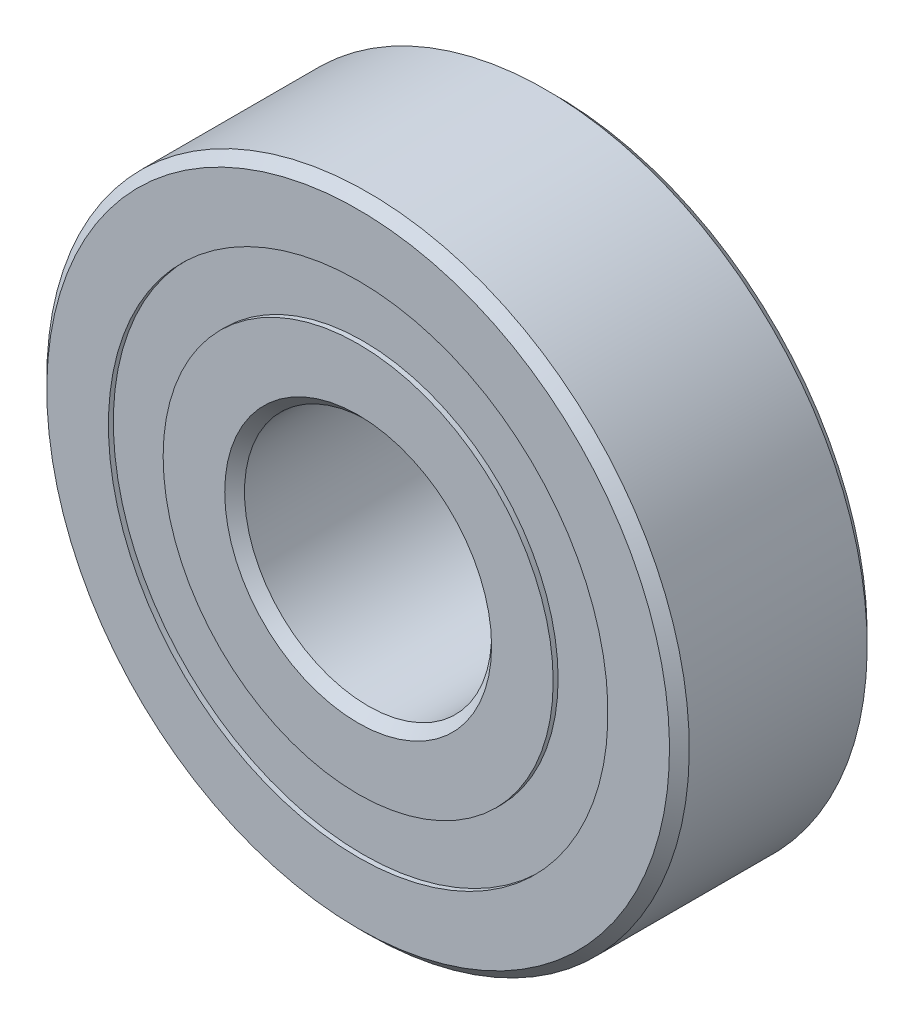
from build123d import *

# Parameters (mm, degrees)
CIRPATTERN1_COUNT = 10
SKETCH5_W         = 1.705369704
SKETCH5_H         = 2.215384616


with BuildPart() as part:
    # Sketch7 → Revolve6 (revolve)
    with BuildSketch(Plane(origin=(0, 0, 0), x_dir=(0, 0, -1), z_dir=(1, 0, 0))):
        with BuildLine():
            Line((3.6, 13), (4, 12.6))
            Line((4, 12.6), (4, 10.107692308))
            Line((4, 10.107692308), (1.777777778, 10.107692308))
            ThreePointArc((1.777777778, 10.107692308), (0, 11.094630296), (-1.777777778, 10.107692308))
            Line((-1.777777778, 10.107692308), (-4, 10.107692308))
            Line((-4, 10.107692308), (-4, 12.6))
            Line((-4, 12.6), (-3.6, 13))
            Line((-3.6, 13), (3.6, 13))
        make_face()
    revolve(axis=Axis((0, 0, 4), (0, 0, -1)))


with BuildPart() as body_2:
    # Sketch3 → Revolve3 (revolve)
    with BuildSketch(Plane(origin=(0, 0, 0), x_dir=(0, 0, -1), z_dir=(1, 0, 0))):
        with BuildLine():
            Line((-3.6, 5), (-4, 5.4))
            Line((-4, 5.4), (-4, 7.892307692))
            Line((-4, 7.892307692), (-1.777777778, 7.892307692))
            ThreePointArc((-1.777777778, 7.892307692), (0, 6.905369704), (1.777777778, 7.892307692))
            Line((1.777777778, 7.892307692), (4, 7.892307692))
            Line((4, 7.892307692), (4, 5.4))
            Line((4, 5.4), (3.6, 5))
            Line((3.6, 5), (-3.6, 5))
        make_face()
    revolve(axis=Axis((0, 0, 4), (0, 0, -1)))


with BuildPart() as body_3:
    # Sketch4 → Revolve4 (revolve)
    with BuildSketch(Plane(origin=(0, 0, 0), x_dir=(0, 0, -1), z_dir=(1, 0, 0))):
        with BuildLine():
            Line((-2.094630296, 9), (2.094630296, 9))
            ThreePointArc((2.094630296, 9), (0, 11.094630296), (-2.094630296, 9))
        make_face()
    revolve(axis=Axis((0, 9, 2.094630296), (0, 0, -1)))


with BuildPart() as cirpattern1_1:
    # CirPattern1: pattern copy
    add(body_3.part.rotate(Axis((0, 0, 0), (0, 0, 1)), 1 * 360 / CIRPATTERN1_COUNT))


with BuildPart() as cirpattern1_2:
    # CirPattern1: pattern copy
    add(body_3.part.rotate(Axis((0, 0, 0), (0, 0, 1)), 2 * 360 / CIRPATTERN1_COUNT))


with BuildPart() as cirpattern1_3:
    # CirPattern1: pattern copy
    add(body_3.part.rotate(Axis((0, 0, 0), (0, 0, 1)), 3 * 360 / CIRPATTERN1_COUNT))


with BuildPart() as cirpattern1_4:
    # CirPattern1: pattern copy
    add(body_3.part.rotate(Axis((0, 0, 0), (0, 0, 1)), 4 * 360 / CIRPATTERN1_COUNT))


with BuildPart() as cirpattern1_5:
    # CirPattern1: pattern copy
    add(body_3.part.rotate(Axis((0, 0, 0), (0, 0, 1)), 5 * 360 / CIRPATTERN1_COUNT))


with BuildPart() as cirpattern1_6:
    # CirPattern1: pattern copy
    add(body_3.part.rotate(Axis((0, 0, 0), (0, 0, 1)), 6 * 360 / CIRPATTERN1_COUNT))


with BuildPart() as cirpattern1_7:
    # CirPattern1: pattern copy
    add(body_3.part.rotate(Axis((0, 0, 0), (0, 0, 1)), 7 * 360 / CIRPATTERN1_COUNT))


with BuildPart() as cirpattern1_8:
    # CirPattern1: pattern copy
    add(body_3.part.rotate(Axis((0, 0, 0), (0, 0, 1)), 8 * 360 / CIRPATTERN1_COUNT))


with BuildPart() as cirpattern1_9:
    # CirPattern1: pattern copy
    add(body_3.part.rotate(Axis((0, 0, 0), (0, 0, 1)), 9 * 360 / CIRPATTERN1_COUNT))


with BuildPart() as body_13:
    # Sketch5 → Revolve5 (revolve)
    with BuildSketch(Plane(origin=(0, 0, 0), x_dir=(0, 0, -1), z_dir=(1, 0, 0))):
        with Locations((-2.947315148, 9)):
            Rectangle(SKETCH5_W, SKETCH5_H)
        with Locations((2.947315148, 9)):
            Rectangle(SKETCH5_W, SKETCH5_H)
    revolve(axis=Axis((0, 0, 4), (0, 0, -1)))


solid = Compound([part.part, body_2.part, body_3.part, cirpattern1_1.part, cirpattern1_2.part, cirpattern1_3.part, cirpattern1_4.part, cirpattern1_5.part, cirpattern1_6.part, cirpattern1_7.part, cirpattern1_8.part, cirpattern1_9.part, body_13.part])
